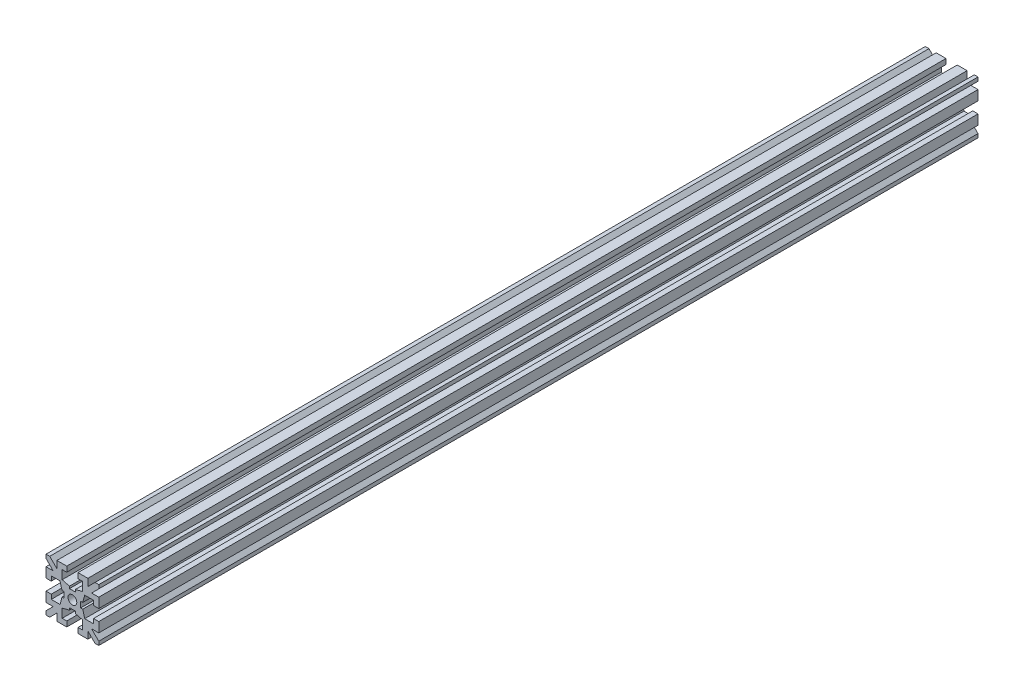
from build123d import *

# Parameters (mm, degrees)
RESSALTO_EXTRUS_O1_DEPTH   = 125
ESPELHAR2_COPY_1_DEPTH     = 125
ESBO_O2_R                  = 1.25
CORTE_EXTRUS_O1_DEPTH      = 1
CORTE_EXTRUS_O1_DEPTH_BACK = 251


with BuildPart() as part:
    # Esboço1 → Ressalto-extrusão1 (new body, symmetric)
    with BuildSketch(Plane.XY):
        Polygon((0, 2.35), (-0.825, 2.35), (-0.825, 2.95), (-2.9, 3.5), (-2.9, 6), (-1.6, 6), (-1.6, 7.5), (-4.4, 7.5), (-4.4, 5.460660172), (-6.439339828, 7.5), (-7.5, 7.5), (-7.5, 6.439339828), (-5.460660172, 4.4), (-7.5, 4.4), (-7.5, 1.6), (-6, 1.6), (-6, 2.9), (-3.5, 2.9), (-2.95, 0.825), (-2.35, 0.825), (-2.35, 0), (0, 0), align=None)
    ressalto_extrus_o1 = extrude(amount=RESSALTO_EXTRUS_O1_DEPTH, both=True)

    # Espelhar1: Ressalto-extrusão1 across plane
    add(ressalto_extrus_o1.mirror(Plane.ZX))

    # Espelhar2: Ressalto-extrusão1 across plane
    add(ressalto_extrus_o1.mirror(Plane(origin=(0, 0, 0), x_dir=(0, 0, 1), z_dir=(1, 0, 0))))

    # Espelhar2 copy 1 sketch → Espelhar2 copy 1 (add, symmetric)
    with BuildSketch(Plane(origin=(0, 0, 0), x_dir=(-1, 0, 0), z_dir=(0, 0, 1))):
        Polygon((0, 2.35), (-0.825, 2.35), (-0.825, 2.95), (-2.9, 3.5), (-2.9, 6), (-1.6, 6), (-1.6, 7.5), (-4.4, 7.5), (-4.4, 5.460660172), (-6.439339828, 7.5), (-7.5, 7.5), (-7.5, 6.439339828), (-5.460660172, 4.4), (-7.5, 4.4), (-7.5, 1.6), (-6, 1.6), (-6, 2.9), (-3.5, 2.9), (-2.95, 0.825), (-2.35, 0.825), (-2.35, 0), (0, 0), align=None)
    extrude(amount=ESPELHAR2_COPY_1_DEPTH, both=True)

    # Esboço2 → Corte-extrusão1 (cut, two sides)
    with BuildSketch(Plane.XY.offset(125)) as corte_extrus_o1_sk:
        Circle(ESBO_O2_R)
    extrude(amount=CORTE_EXTRUS_O1_DEPTH, mode=Mode.SUBTRACT)
    extrude(corte_extrus_o1_sk.sketch, amount=-CORTE_EXTRUS_O1_DEPTH_BACK, mode=Mode.SUBTRACT)


solid = part.part
